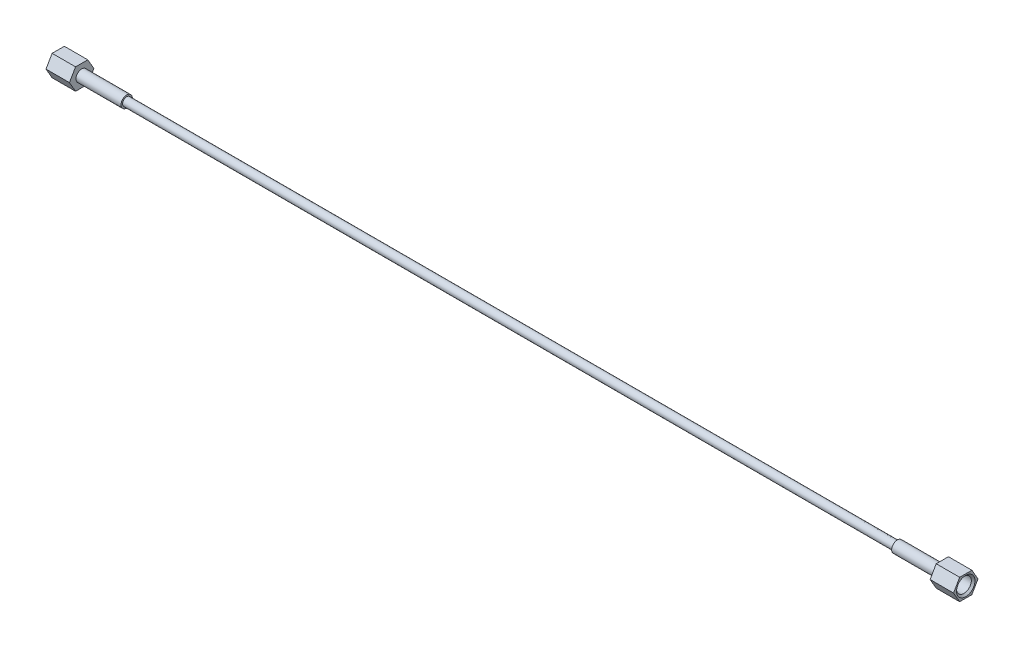
from build123d import *

# Parameters (mm, degrees)
EXTRUDE2_DEPTH = 15.748
CHAMFER2_SIZE  = 1.240155


with BuildPart() as part:
    # Sketch5 → Extrude2 (new body)
    with BuildSketch(Plane(origin=(-6.858, 0, 0), x_dir=(0, 0, -1), z_dir=(1, 0, 0))):
        Polygon((4.106115114, 7.112), (-4.106115114, 7.112), (-8.212230229, 0), (-4.106115114, -7.112), (4.106115114, -7.112), (8.212230229, 0), align=None)
    extrude(amount=EXTRUDE2_DEPTH)

    # Sketch6 → Hole2 (revolve, cut)
    with BuildSketch(Plane(origin=(8.89, 0, 0), x_dir=(0, 0, -1), z_dir=(0, 1, 0))):
        Polygon((0, 0), (0, 15.748), (3.8354, 15.748), (3.8354, 9.566100386), (4.96062, 8.89), (4.96062, 0), align=None)
    revolve(axis=Axis((15.020023899, 0, 0), (-1, 0, 0)), mode=Mode.SUBTRACT)

    # Chamfer2
    chamfer2_edges = [part.edges().sort_by_distance(p)[0] for p in [
        (8.89, 0, 4.96062),
    ]]
    chamfer(chamfer2_edges, length=CHAMFER2_SIZE)


with BuildPart() as body_2:
    # Sketch8 → Revolve2 (revolve)
    with BuildSketch(Plane(origin=(0, 0, 0), x_dir=(-1, 0, 0), z_dir=(0, 0, -1)), mode=Mode.PRIVATE) as revolve2_sk:
        Polygon((0.691362245, 3.81), (2.385428675, 0.9906), (589.434571325, 0.9906), (591.128637755, 3.81), (554.736, 3.81), (554.736, 2.7686), (37.084, 2.7686), (37.084, 3.81), align=None)
    revolve(revolve2_sk.sketch.rotate(Axis((-0.691362245, 0, 0), (-1, 0, 0)), 270), axis=Axis((-0.691362245, 0, 0), (-1, 0, 0)))  # turned: the seam where the file's is


with BuildPart() as body_3:
    # Mirror2: mirrored copy
    add(part.part.mirror(Plane(origin=(-295.91, 0, 0), x_dir=(0, 0, 1), z_dir=(1, 0, 0))))


solid = Compound([part.part, body_2.part, body_3.part])
